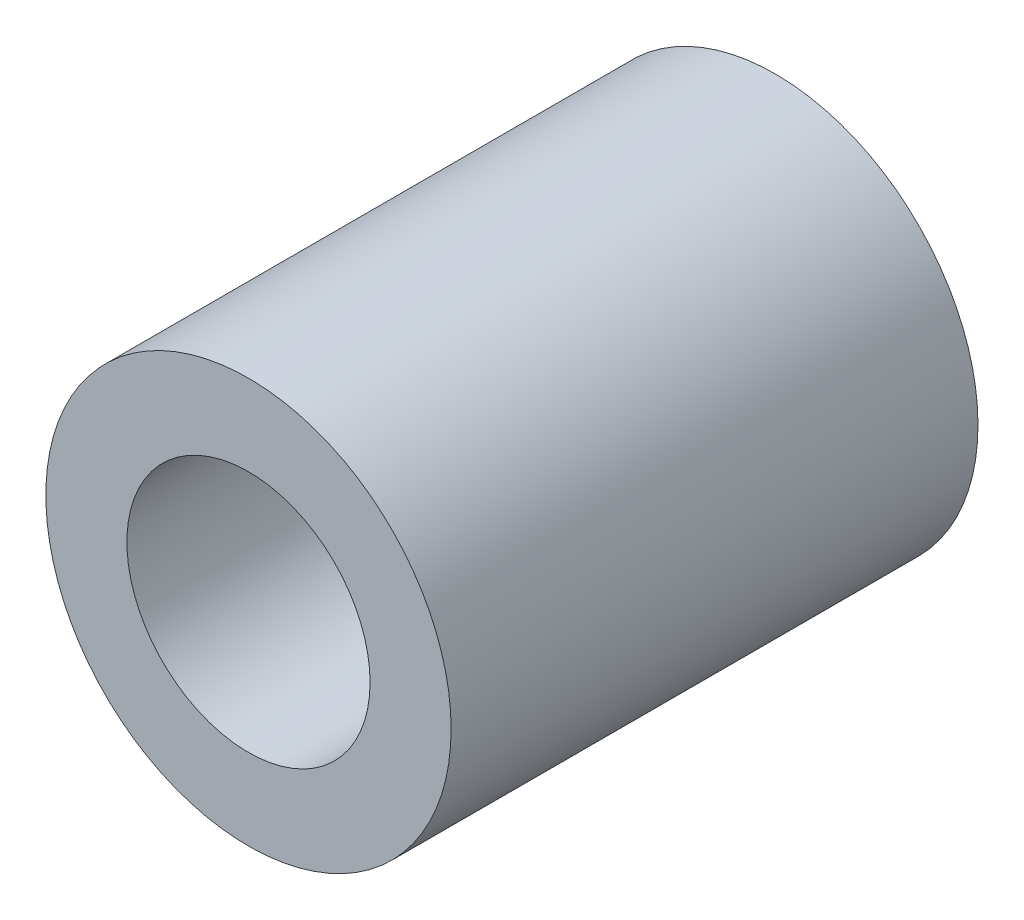
from build123d import *

# Parameters (mm, degrees)
ESQUISSE1_R      = 5
ESQUISSE1_R_2    = 3
EXTRUSION1_DEPTH = 13


with BuildPart() as part:
    # Esquisse1 → Extrusion1 (new body)
    with BuildSketch(Plane.XY):
        Circle(ESQUISSE1_R)
        Circle(ESQUISSE1_R_2, mode=Mode.SUBTRACT)
    extrude(amount=EXTRUSION1_DEPTH)


solid = part.part
